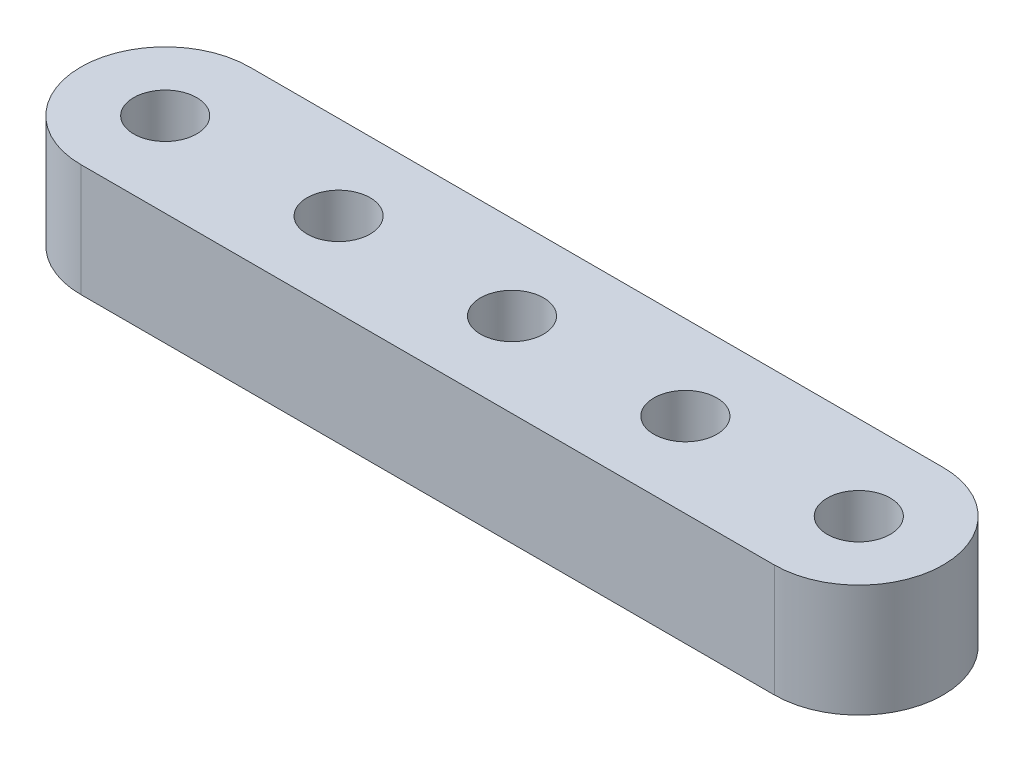
from build123d import *

# Parameters (mm, degrees)
SKETCH1_R           = 1.778
BOSS_EXTRUDE1_DEPTH = 6.35


with BuildPart() as part:
    # Sketch1 → Boss-Extrude1 (new body)
    with BuildSketch(Plane(origin=(0, 6.35, 0), x_dir=(1, 0, 0), z_dir=(0, 1, 0))):
        with BuildLine():
            Line((19.558, 4.7625), (-19.558, 4.7625))
            ThreePointArc((-19.558, 4.7625), (-24.3205, 0), (-19.558, -4.7625))
            Line((-19.558, -4.7625), (19.558, -4.7625))
            ThreePointArc((19.558, -4.7625), (24.3205, 0), (19.558, 4.7625))
        make_face()
        with Locations((19.558, 0)):
            Circle(SKETCH1_R, mode=Mode.SUBTRACT)
        with Locations((9.779, 0)):
            Circle(SKETCH1_R, mode=Mode.SUBTRACT)
        Circle(SKETCH1_R, mode=Mode.SUBTRACT)
        with Locations((-9.779, 0)):
            Circle(SKETCH1_R, mode=Mode.SUBTRACT)
        with Locations((-19.558, 0)):
            Circle(SKETCH1_R, mode=Mode.SUBTRACT)
    extrude(amount=-BOSS_EXTRUDE1_DEPTH)


solid = part.part
